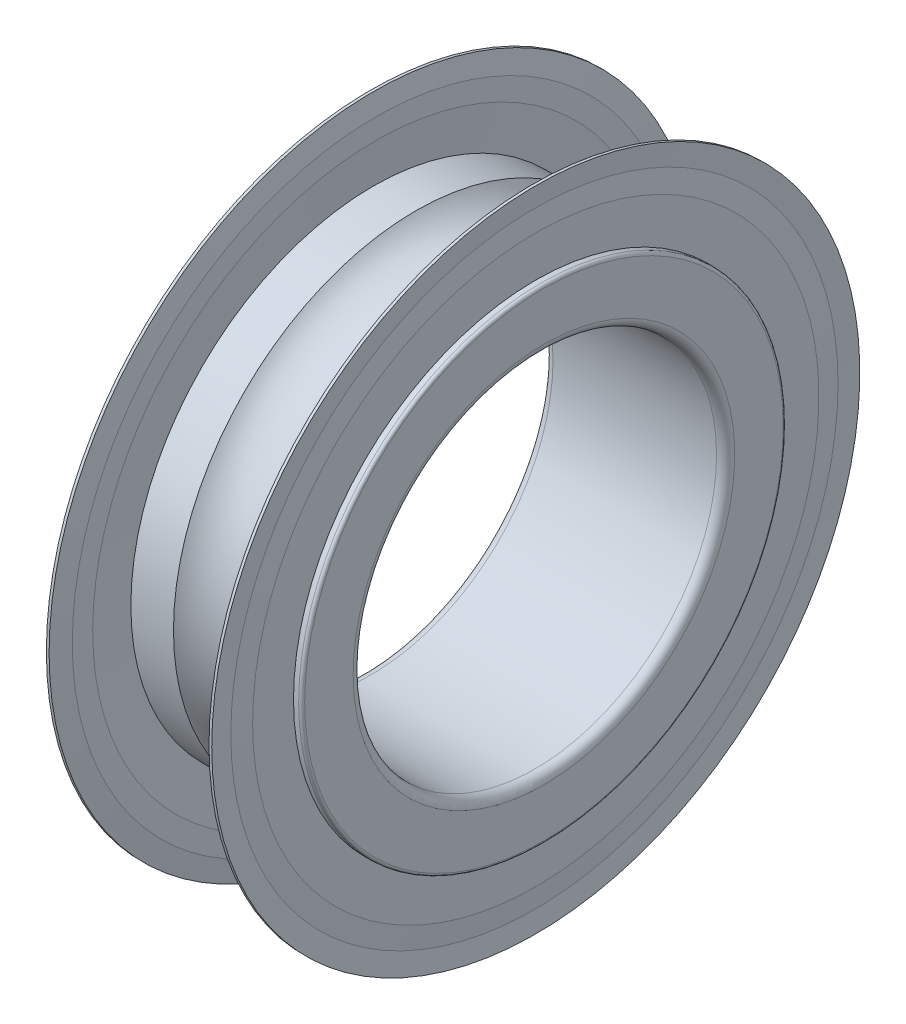
from build123d import *


with BuildPart() as part:
    # Sketch1 → Revolve1 (revolve)
    with BuildSketch(Plane.XY):
        with BuildLine():
            Line((0, 7.9), (0, 6.3))
            ThreePointArc((0, 6.3), (0.087867966, 6.087867966), (0.3, 6))
            Line((0.3, 6), (5.7, 6))
            ThreePointArc((5.7, 6), (5.912132034, 6.087867966), (6, 6.3))
            Line((6, 6.3), (6, 7.9))
            ThreePointArc((6, 7.9), (5.970710678, 7.970710678), (5.9, 8))
            Line((5.9, 8), (4.232946167, 8))
            ThreePointArc((4.232946167, 8), (3, 7.4125), (1.767053833, 8))
            Line((1.767053833, 8), (0.1, 8))
            ThreePointArc((0.1, 8), (0.029289322, 7.970710678), (0, 7.9))
        make_face()
    revolve(axis=Axis((50, 0, 0), (-1, 0, 0)))

    # Sketch2 → Revolve2 (revolve)
    with BuildSketch(Plane.XY):
        Polygon((0.27, 10.7), (0.315, 10.025), (0.27, 9.35), (0.27, 8), (0.36, 8), (0.45, 9.35), (0.45, 10.025), (0.36, 10.7), align=None)
    revolve(axis=Axis((50, 0, 0), (-1, 0, 0)))

    # Sketch3 → Revolve3 (revolve)
    with BuildSketch(Plane.XY):
        Polygon((5.55, 10.025), (5.55, 9.35), (5.64, 8), (5.73, 8), (5.73, 9.35), (5.685, 10.025), (5.73, 10.7), (5.64, 10.7), align=None)
    revolve(axis=Axis((50, 0, 0), (-1, 0, 0)))


solid = part.part
